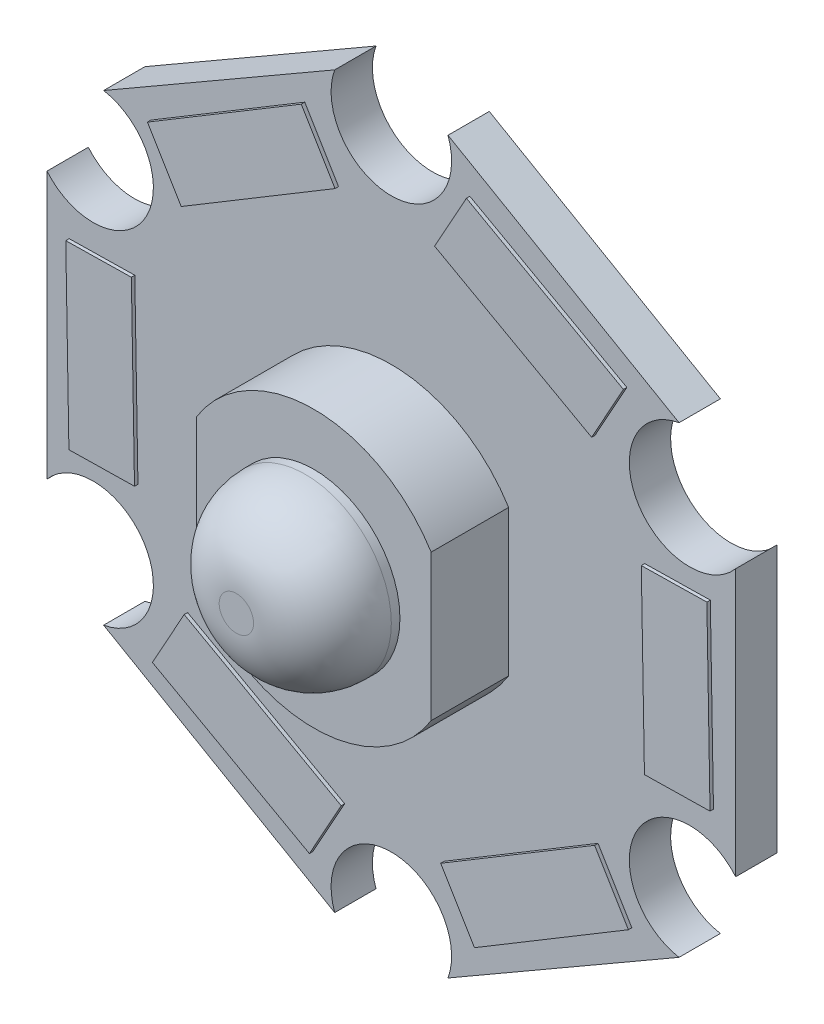
from build123d import *

# Parameters (mm, degrees)
SALIENTE_EXTRUIR1_DEPTH   = 1.2
SALIENTE_EXTRUIR2_DEPTH   = 0.1
SALIENTE_EXTRUIR2_2_DEPTH = 0.1
SALIENTE_EXTRUIR2_3_DEPTH = 0.1
SALIENTE_EXTRUIR2_4_DEPTH = 0.1
SALIENTE_EXTRUIR2_5_DEPTH = 0.1
SALIENTE_EXTRUIR2_6_DEPTH = 0.1
SALIENTE_EXTRUIR3_DEPTH   = 2.25
CROQUIS4_R                = 2.5
SALIENTE_EXTRUIR4_DEPTH   = 2.25
REDONDEO4_R               = 2


with BuildPart() as part:
    # Croquis1 → Saliente-Extruir1 (new body)
    with BuildSketch(Plane.XY):
        with BuildLine():
            Line((-10, 3.87413111), (-10, -3.87413111))
            ThreePointArc((-10, -3.87413111), (-7.144709581, -4.125), (-8.355095959, -6.723188483))
            Line((-8.355095959, -6.723188483), (-1.644904041, -10.597319593))
            ThreePointArc((-1.644904041, -10.597319593), (0, -8.25), (1.644904041, -10.597319593))
            Line((1.644904041, -10.597319593), (8.355095959, -6.723188483))
            ThreePointArc((8.355095959, -6.723188483), (7.144709581, -4.125), (10, -3.87413111))
            Line((10, -3.87413111), (10, 3.87413111))
            ThreePointArc((10, 3.87413111), (7.144709581, 4.125), (8.355095959, 6.723188483))
            Line((8.355095959, 6.723188483), (1.644904041, 10.597319593))
            ThreePointArc((1.644904041, 10.597319593), (0, 8.25), (-1.644904041, 10.597319593))
            Line((-1.644904041, 10.597319593), (-8.355095959, 6.723188483))
            ThreePointArc((-8.355095959, 6.723188483), (-7.144709581, 4.125), (-10, 3.87413111))
        make_face()
    extrude(amount=SALIENTE_EXTRUIR1_DEPTH)


with BuildPart() as body_2:
    # Croquis2 → Saliente-Extruir2 (new body)
    with BuildSketch(Plane.XY.offset(1.2)):
        Polygon((2.279814444, 9.380200395), (6.839443333, 6.853177155), (5.916048556, 5.187051796), (1.356419667, 7.714075036), align=None)
    extrude(amount=SALIENTE_EXTRUIR2_DEPTH)


with BuildPart() as body_3:
    # Croquis2 → Saliente-Extruir2 2 (new body)
    with BuildSketch(Plane.XY.offset(1.2)):
        Polygon((9.263399056, 2.715722973), (9.354747179, -2.496543097), (7.450142904, -2.529922441), (7.358794781, 2.682343628), align=None)
    extrude(amount=SALIENTE_EXTRUIR2_2_DEPTH)


with BuildPart() as body_4:
    # Croquis2 → Saliente-Extruir2 3 (new body)
    with BuildSketch(Plane.XY.offset(1.2)):
        Polygon((6.983584612, -6.664477422), (2.515303846, -9.349720252), (1.534094348, -7.716974237), (6.002375114, -5.031731408), align=None)
    extrude(amount=SALIENTE_EXTRUIR2_3_DEPTH)


with BuildPart() as body_5:
    # Croquis2 → Saliente-Extruir2 4 (new body)
    with BuildSketch(Plane.XY.offset(1.2)):
        Polygon((-2.279814444, -9.380200395), (-6.839443333, -6.853177155), (-5.916048556, -5.187051796), (-1.356419667, -7.714075036), align=None)
    extrude(amount=SALIENTE_EXTRUIR2_4_DEPTH)


with BuildPart() as body_6:
    # Croquis2 → Saliente-Extruir2 5 (new body)
    with BuildSketch(Plane.XY.offset(1.2)):
        Polygon((-9.263399056, -2.715722973), (-9.354747179, 2.496543097), (-7.450142904, 2.529922441), (-7.358794781, -2.682343628), align=None)
    extrude(amount=SALIENTE_EXTRUIR2_5_DEPTH)


with BuildPart() as body_7:
    # Croquis2 → Saliente-Extruir2 6 (new body)
    with BuildSketch(Plane.XY.offset(1.2)):
        Polygon((-6.983584612, 6.664477422), (-2.515303846, 9.349720252), (-1.534094348, 7.716974237), (-6.002375114, 5.031731408), align=None)
    extrude(amount=SALIENTE_EXTRUIR2_6_DEPTH)


with BuildPart() as body_8:
    # Croquis3 → Saliente-Extruir3 (new body)
    with BuildSketch(Plane.XY.offset(1.2)):
        with BuildLine():
            Line((-3.406583147, 2.118728542), (-3.406583147, -2.118728542))
            ThreePointArc((-3.406583147, -2.118728542), (0, -4.01171028), (3.406583147, -2.118728542))
            Line((3.406583147, -2.118728542), (3.406583147, 2.118728542))
            ThreePointArc((3.406583147, 2.118728542), (0, 4.01171028), (-3.406583147, 2.118728542))
        make_face()
    extrude(amount=SALIENTE_EXTRUIR3_DEPTH)

    # Croquis4 → Saliente-Extruir4 (add)
    with BuildSketch(Plane.XY.offset(3.45)):
        Circle(CROQUIS4_R)
    extrude(amount=SALIENTE_EXTRUIR4_DEPTH)

    # Redondeo4
    redondeo4_edges = [body_8.edges().sort_by_distance(p)[0] for p in [
        (-2.5, 0, 5.7),
    ]]
    fillet(redondeo4_edges, radius=REDONDEO4_R)


solid = Compound([part.part, body_2.part, body_3.part, body_4.part, body_5.part, body_6.part, body_7.part, body_8.part])
